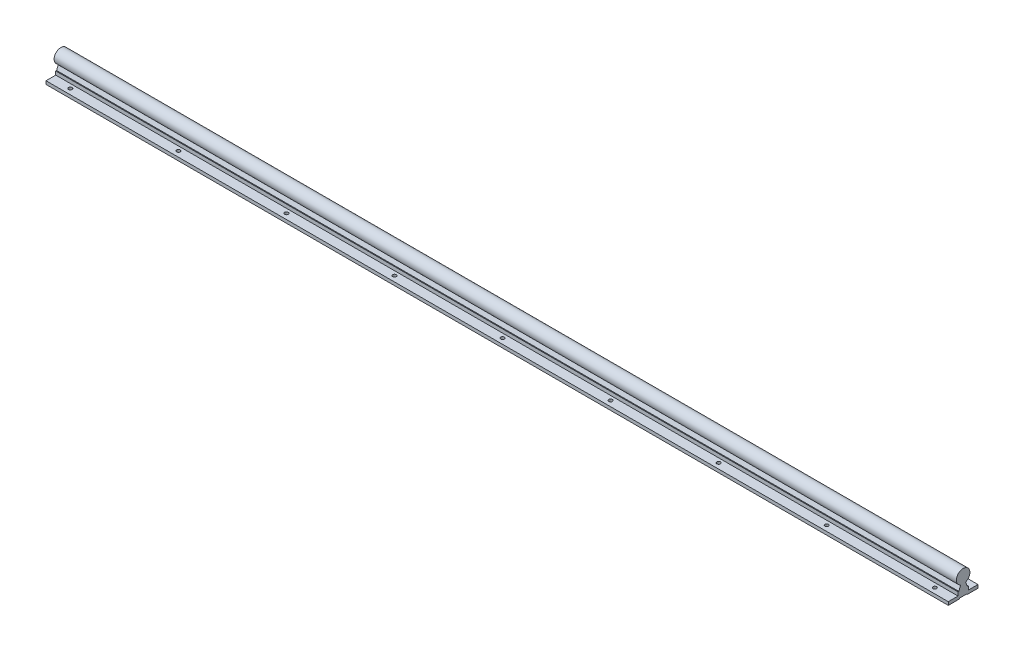
from build123d import *

# Parameters (mm, degrees)
EXTRUDE_1_DEPTH         = 1670
HOLE_WIZARD_6_6_6_6_1_D = 6.6
PATTERN_LINEAR_1_COUNT  = 9
PATTERN_LINEAR_1_PITCH  = 200


with BuildPart() as part:
    # 草图1 → 凸台-拉伸1 (new body)
    with BuildSketch(Plane(origin=(0, 0, 0), x_dir=(0, 0, -1), z_dir=(1, 0, 0))):
        with BuildLine():
            Line((38.023703704, 12.710240583), (38.023703704, 6.710240583))
            Line((38.023703704, 6.710240583), (18.023703704, 6.710240583))
            Line((18.023703704, 6.710240583), (16.823703704, 7.910240583))
            Line((16.823703704, 7.910240583), (4.223703704, 7.910240583))
            Line((4.223703704, 7.910240583), (3.023703704, 6.710240583))
            Line((3.023703704, 6.710240583), (-16.976296296, 6.710240583))
            Line((-16.976296296, 6.710240583), (-16.976296296, 12.710240583))
            Line((-16.976296296, 12.710240583), (1.023703704, 12.710240583))
            Line((1.023703704, 12.710240583), (1.023703704, 19.410240583))
            Line((1.023703704, 19.410240583), (2.593703704, 19.410240583))
            Line((2.593703704, 19.410240583), (5.975416608, 28.06708446))
            ThreePointArc((5.975416608, 28.06708446), (10.523703704, 52.210240583), (15.0719908, 28.06708446))
            Line((15.0719908, 28.06708446), (18.453703704, 19.410240583))
            Line((18.453703704, 19.410240583), (20.023703704, 19.410240583))
            Line((20.023703704, 19.410240583), (20.023703704, 12.710240583))
            Line((20.023703704, 12.710240583), (38.023703704, 12.710240583))
        make_face()
    extrude(amount=EXTRUDE_1_DEPTH)

    # Ø6.6 (6.6) 直径孔1 (through all)
    with Locations(Plane(origin=(35, 12.710240583, -28.023703704), x_dir=(0, 0, 1), z_dir=(0, 1, 0))):
        with Locations((0, 0), (35, 0)):
            hole_wizard_6_6_6_6_1 = Hole(HOLE_WIZARD_6_6_6_6_1_D / 2)

    # 阵列(线性)1: Ø6.6 (6.6) 直径孔1 ×9
    with Locations(*[(i * PATTERN_LINEAR_1_PITCH, 0, 0) for i in range(1, PATTERN_LINEAR_1_COUNT)]):
        add(hole_wizard_6_6_6_6_1, mode=Mode.SUBTRACT)


solid = part.part
